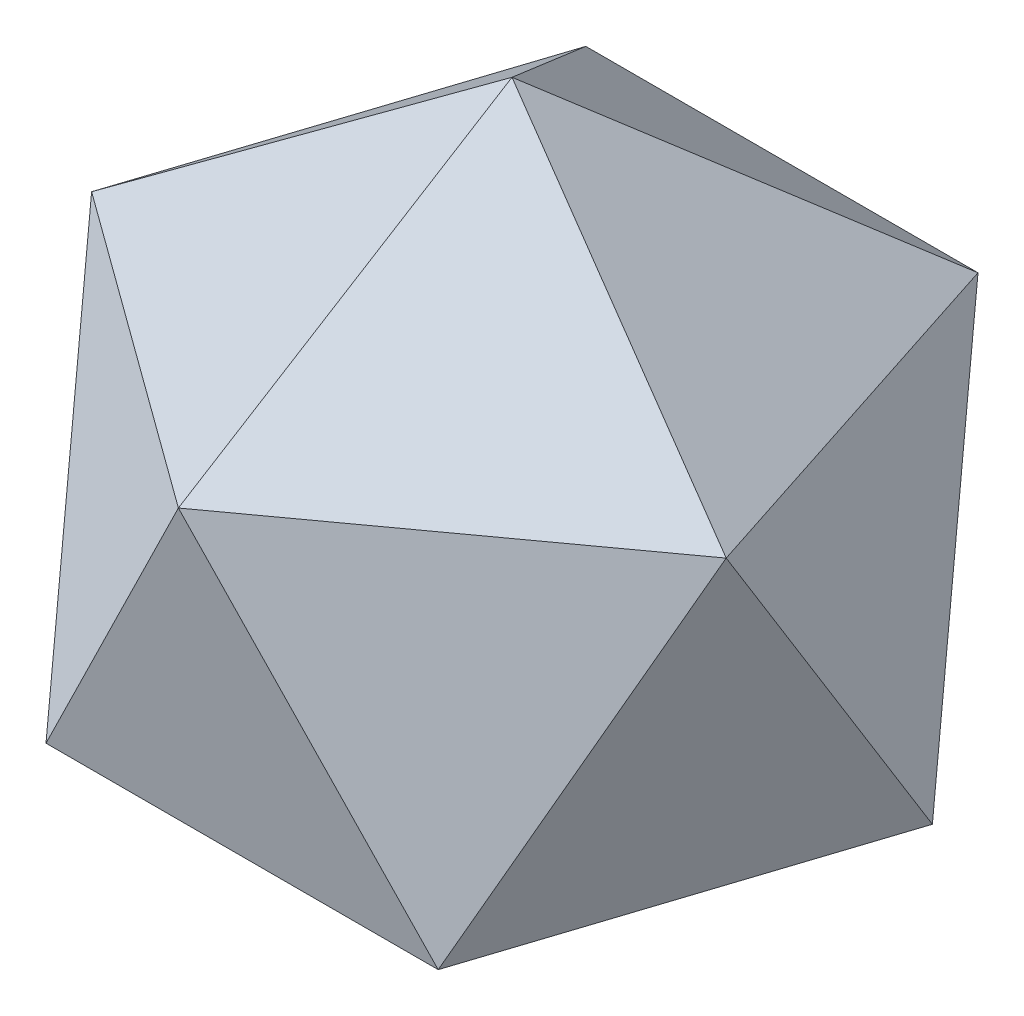
from build123d import *

# Parameters (mm, degrees)
CIRPATTERN1_9_2_ANGLE   = -216
CIRPATTERN1_6_4_ANGLE   = -144
CIRPATTERN1_10_6_ANGLE  = -216
CIRPATTERN1_14_8_ANGLE  = -288
CIRPATTERN1_13_11_ANGLE = -288
CIRPATTERN1_15_13_ANGLE = -288
CIRPATTERN1_16_15_ANGLE = -288
CIRPATTERN1_11_17_ANGLE = -216
CIRPATTERN1_8_19_ANGLE  = -144
CIRPATTERN1_12_21_ANGLE = -216
CIRPATTERN1_7_23_ANGLE  = -144
CIRPATTERN1_3_25_ANGLE  = -72
CIRPATTERN1_4_27_ANGLE  = -72
CIRPATTERN1_5_32_ANGLE  = -144
CIRPATTERN1_34_ANGLE    = -72
CIRPATTERN1_2_36_ANGLE  = -72


with BuildPart() as body_1:
    # Sketch2 → Surface-Fill1: a flat surface bounded by the sketch
    with BuildSketch(Plane(origin=(3.918568349, -8.726779962, -5.393446629), x_dir=(-0.9341723589627158, -0.303530999103343, -0.18759247408507992), z_dir=(0.3568220897730899, -0.7946544722917661, -0.4911234731884233)), mode=Mode.PRIVATE) as surface_fill1_1_region:
        Polygon((4.194695241, 19.021130326), (4.194695241, -7.26542528), (-18.570129692, 5.877852523), align=None)
    surface_fill1_1 = surface_fill1_1_region.sketch.faces()[0]
    # CirPattern1 9: a copy of that surface (a pattern of surface bodies)
    cirpattern1_9_2 = surface_fill1_1.rotate(Axis((0, 0, 0), (0, 1, 0)), CIRPATTERN1_9_2_ANGLE)
    # Sketch3 → Surface-Fill2: a flat surface bounded by the sketch
    with BuildSketch(Plane(origin=(10.258945124, -3.333333333, -14.120226592), x_dir=(0.8164965809277261, 0.13264791052512165, 0.5619055660577252), z_dir=(-0.5773502691896257, 0.18759247408507984, 0.7946544722917663)), mode=Mode.PRIVATE) as surface_fill2_3_region:
        Polygon((3.532571656, 25.918778373), (13.481164945, 1.587553636), (-12.564590426, 5.137431484), align=None)
    surface_fill2_3 = surface_fill2_3_region.sketch.faces()[0]
    # CirPattern1 6: a copy of that surface (a pattern of surface bodies)
    cirpattern1_6_4 = surface_fill2_3.rotate(Axis((0, 0, 0), (0, 1, 0)), CIRPATTERN1_6_4_ANGLE)
    # Sketch3 → Surface-Fill2: a flat surface bounded by the sketch
    with BuildSketch(Plane(origin=(10.258945124, -3.333333333, -14.120226592), x_dir=(0.8164965809277261, 0.13264791052512165, 0.5619055660577252), z_dir=(-0.5773502691896257, 0.18759247408507984, 0.7946544722917663)), mode=Mode.PRIVATE) as surface_fill2_5_region:
        Polygon((3.532571656, 25.918778373), (13.481164945, 1.587553636), (-12.564590426, 5.137431484), align=None)
    surface_fill2_5 = surface_fill2_5_region.sketch.faces()[0]
    # CirPattern1 10: a copy of that surface (a pattern of surface bodies)
    cirpattern1_10_6 = surface_fill2_5.rotate(Axis((0, 0, 0), (0, 1, 0)), CIRPATTERN1_10_6_ANGLE)
    # Sketch3 → Surface-Fill2: a flat surface bounded by the sketch
    with BuildSketch(Plane(origin=(10.258945124, -3.333333333, -14.120226592), x_dir=(0.8164965809277261, 0.13264791052512165, 0.5619055660577252), z_dir=(-0.5773502691896257, 0.18759247408507984, 0.7946544722917663)), mode=Mode.PRIVATE) as surface_fill2_7_region:
        Polygon((3.532571656, 25.918778373), (13.481164945, 1.587553636), (-12.564590426, 5.137431484), align=None)
    surface_fill2_7 = surface_fill2_7_region.sketch.faces()[0]
    # CirPattern1 14: a copy of that surface (a pattern of surface bodies)
    cirpattern1_14_8 = surface_fill2_7.rotate(Axis((0, 0, 0), (0, 1, 0)), CIRPATTERN1_14_8_ANGLE)
    # Sketch6 → Surface-Fill4: a flat surface bounded by the sketch
    with BuildSketch(Plane(origin=(16.599321899, 22.847006554, -5.393446629), x_dir=(0.8164965809277256, -0.561905566057726, 0.13264791052512173), z_dir=(0.5773502691896265, 0.7946544722917657, -0.1875924740850797)), mode=Mode.PRIVATE) as surface_fill4_9_region:
        Polygon((5.715821007, -11.862416603), (-4.232772282, 12.468808133), (-20.329934365, -8.312538756), align=None)
    surface_fill4_9 = surface_fill4_9_region.sketch.faces()[0]
    # Sketch2 → Surface-Fill1: a flat surface bounded by the sketch
    with BuildSketch(Plane(origin=(3.918568349, -8.726779962, -5.393446629), x_dir=(-0.9341723589627158, -0.303530999103343, -0.18759247408507992), z_dir=(0.3568220897730899, -0.7946544722917661, -0.4911234731884233)), mode=Mode.PRIVATE) as surface_fill1_10_region:
        Polygon((4.194695241, 19.021130326), (4.194695241, -7.26542528), (-18.570129692, 5.877852523), align=None)
    surface_fill1_10 = surface_fill1_10_region.sketch.faces()[0]
    # CirPattern1 13: a copy of that surface (a pattern of surface bodies)
    cirpattern1_13_11 = surface_fill1_10.rotate(Axis((0, 0, 0), (0, 1, 0)), CIRPATTERN1_13_11_ANGLE)
    # Sketch5 → Surface-Fill3: a flat surface bounded by the sketch
    with BuildSketch(Plane(origin=(20.517890248, 4.120226592, -6.666666667), x_dir=(0.2975901052216016, 0.059759490383281426, 0.9528215638740166), z_dir=(-0.9341723589627157, -0.1875924740850806, 0.3035309991033427)), mode=Mode.PRIVATE) as surface_fill3_12_region:
        Polygon((-11.989131764, 19.33536107), (-0.255203491, -4.186924808), (14.248729497, 17.736098102), align=None)
    surface_fill3_12 = surface_fill3_12_region.sketch.faces()[0]
    # CirPattern1 15: a copy of that surface (a pattern of surface bodies)
    cirpattern1_15_13 = surface_fill3_12.rotate(Axis((0, 0, 0), (0, 1, 0)), CIRPATTERN1_15_13_ANGLE)
    # Sketch6 → Surface-Fill4: a flat surface bounded by the sketch
    with BuildSketch(Plane(origin=(16.599321899, 22.847006554, -5.393446629), x_dir=(0.8164965809277256, -0.561905566057726, 0.13264791052512173), z_dir=(0.5773502691896265, 0.7946544722917657, -0.1875924740850797)), mode=Mode.PRIVATE) as surface_fill4_14_region:
        Polygon((5.715821007, -11.862416603), (-4.232772282, 12.468808133), (-20.329934365, -8.312538756), align=None)
    surface_fill4_14 = surface_fill4_14_region.sketch.faces()[0]
    # CirPattern1 16: a copy of that surface (a pattern of surface bodies)
    cirpattern1_16_15 = surface_fill4_14.rotate(Axis((0, 0, 0), (0, 1, 0)), CIRPATTERN1_16_15_ANGLE)
    # Sketch5 → Surface-Fill3: a flat surface bounded by the sketch
    with BuildSketch(Plane(origin=(20.517890248, 4.120226592, -6.666666667), x_dir=(0.2975901052216016, 0.059759490383281426, 0.9528215638740166), z_dir=(-0.9341723589627157, -0.1875924740850806, 0.3035309991033427)), mode=Mode.PRIVATE) as surface_fill3_16_region:
        Polygon((-11.989131764, 19.33536107), (-0.255203491, -4.186924808), (14.248729497, 17.736098102), align=None)
    surface_fill3_16 = surface_fill3_16_region.sketch.faces()[0]
    # CirPattern1 11: a copy of that surface (a pattern of surface bodies)
    cirpattern1_11_17 = surface_fill3_16.rotate(Axis((0, 0, 0), (0, 1, 0)), CIRPATTERN1_11_17_ANGLE)
    # Sketch6 → Surface-Fill4: a flat surface bounded by the sketch
    with BuildSketch(Plane(origin=(16.599321899, 22.847006554, -5.393446629), x_dir=(0.8164965809277256, -0.561905566057726, 0.13264791052512173), z_dir=(0.5773502691896265, 0.7946544722917657, -0.1875924740850797)), mode=Mode.PRIVATE) as surface_fill4_18_region:
        Polygon((5.715821007, -11.862416603), (-4.232772282, 12.468808133), (-20.329934365, -8.312538756), align=None)
    surface_fill4_18 = surface_fill4_18_region.sketch.faces()[0]
    # CirPattern1 8: a copy of that surface (a pattern of surface bodies)
    cirpattern1_8_19 = surface_fill4_18.rotate(Axis((0, 0, 0), (0, 1, 0)), CIRPATTERN1_8_19_ANGLE)
    # Sketch6 → Surface-Fill4: a flat surface bounded by the sketch
    with BuildSketch(Plane(origin=(16.599321899, 22.847006554, -5.393446629), x_dir=(0.8164965809277256, -0.561905566057726, 0.13264791052512173), z_dir=(0.5773502691896265, 0.7946544722917657, -0.1875924740850797)), mode=Mode.PRIVATE) as surface_fill4_20_region:
        Polygon((5.715821007, -11.862416603), (-4.232772282, 12.468808133), (-20.329934365, -8.312538756), align=None)
    surface_fill4_20 = surface_fill4_20_region.sketch.faces()[0]
    # CirPattern1 12: a copy of that surface (a pattern of surface bodies)
    cirpattern1_12_21 = surface_fill4_20.rotate(Axis((0, 0, 0), (0, 1, 0)), CIRPATTERN1_12_21_ANGLE)
    # Sketch5 → Surface-Fill3: a flat surface bounded by the sketch
    with BuildSketch(Plane(origin=(20.517890248, 4.120226592, -6.666666667), x_dir=(0.2975901052216016, 0.059759490383281426, 0.9528215638740166), z_dir=(-0.9341723589627157, -0.1875924740850806, 0.3035309991033427)), mode=Mode.PRIVATE) as surface_fill3_22_region:
        Polygon((-11.989131764, 19.33536107), (-0.255203491, -4.186924808), (14.248729497, 17.736098102), align=None)
    surface_fill3_22 = surface_fill3_22_region.sketch.faces()[0]
    # CirPattern1 7: a copy of that surface (a pattern of surface bodies)
    cirpattern1_7_23 = surface_fill3_22.rotate(Axis((0, 0, 0), (0, 1, 0)), CIRPATTERN1_7_23_ANGLE)
    # Sketch5 → Surface-Fill3: a flat surface bounded by the sketch
    with BuildSketch(Plane(origin=(20.517890248, 4.120226592, -6.666666667), x_dir=(0.2975901052216016, 0.059759490383281426, 0.9528215638740166), z_dir=(-0.9341723589627157, -0.1875924740850806, 0.3035309991033427)), mode=Mode.PRIVATE) as surface_fill3_24_region:
        Polygon((-11.989131764, 19.33536107), (-0.255203491, -4.186924808), (14.248729497, 17.736098102), align=None)
    surface_fill3_24 = surface_fill3_24_region.sketch.faces()[0]
    # CirPattern1 3: a copy of that surface (a pattern of surface bodies)
    cirpattern1_3_25 = surface_fill3_24.rotate(Axis((0, 0, 0), (0, 1, 0)), CIRPATTERN1_3_25_ANGLE)
    # Sketch6 → Surface-Fill4: a flat surface bounded by the sketch
    with BuildSketch(Plane(origin=(16.599321899, 22.847006554, -5.393446629), x_dir=(0.8164965809277256, -0.561905566057726, 0.13264791052512173), z_dir=(0.5773502691896265, 0.7946544722917657, -0.1875924740850797)), mode=Mode.PRIVATE) as surface_fill4_26_region:
        Polygon((5.715821007, -11.862416603), (-4.232772282, 12.468808133), (-20.329934365, -8.312538756), align=None)
    surface_fill4_26 = surface_fill4_26_region.sketch.faces()[0]
    # CirPattern1 4: a copy of that surface (a pattern of surface bodies)
    cirpattern1_4_27 = surface_fill4_26.rotate(Axis((0, 0, 0), (0, 1, 0)), CIRPATTERN1_4_27_ANGLE)
    # Sketch2 → Surface-Fill1: a flat surface bounded by the sketch
    with BuildSketch(Plane(origin=(3.918568349, -8.726779962, -5.393446629), x_dir=(-0.9341723589627158, -0.303530999103343, -0.18759247408507992), z_dir=(0.3568220897730899, -0.7946544722917661, -0.4911234731884233)), mode=Mode.PRIVATE) as surface_fill1_28_region:
        Polygon((4.194695241, 19.021130326), (4.194695241, -7.26542528), (-18.570129692, 5.877852523), align=None)
    surface_fill1_28 = surface_fill1_28_region.sketch.faces()[0]
    # Sketch3 → Surface-Fill2: a flat surface bounded by the sketch
    with BuildSketch(Plane(origin=(10.258945124, -3.333333333, -14.120226592), x_dir=(0.8164965809277261, 0.13264791052512165, 0.5619055660577252), z_dir=(-0.5773502691896257, 0.18759247408507984, 0.7946544722917663)), mode=Mode.PRIVATE) as surface_fill2_29_region:
        Polygon((3.532571656, 25.918778373), (13.481164945, 1.587553636), (-12.564590426, 5.137431484), align=None)
    surface_fill2_29 = surface_fill2_29_region.sketch.faces()[0]
    # Sketch5 → Surface-Fill3: a flat surface bounded by the sketch
    with BuildSketch(Plane(origin=(20.517890248, 4.120226592, -6.666666667), x_dir=(0.2975901052216016, 0.059759490383281426, 0.9528215638740166), z_dir=(-0.9341723589627157, -0.1875924740850806, 0.3035309991033427)), mode=Mode.PRIVATE) as surface_fill3_30_region:
        Polygon((-11.989131764, 19.33536107), (-0.255203491, -4.186924808), (14.248729497, 17.736098102), align=None)
    surface_fill3_30 = surface_fill3_30_region.sketch.faces()[0]
    # Sketch2 → Surface-Fill1: a flat surface bounded by the sketch
    with BuildSketch(Plane(origin=(3.918568349, -8.726779962, -5.393446629), x_dir=(-0.9341723589627158, -0.303530999103343, -0.18759247408507992), z_dir=(0.3568220897730899, -0.7946544722917661, -0.4911234731884233)), mode=Mode.PRIVATE) as surface_fill1_31_region:
        Polygon((4.194695241, 19.021130326), (4.194695241, -7.26542528), (-18.570129692, 5.877852523), align=None)
    surface_fill1_31 = surface_fill1_31_region.sketch.faces()[0]
    # CirPattern1 5: a copy of that surface (a pattern of surface bodies)
    cirpattern1_5_32 = surface_fill1_31.rotate(Axis((0, 0, 0), (0, 1, 0)), CIRPATTERN1_5_32_ANGLE)
    # Sketch2 → Surface-Fill1: a flat surface bounded by the sketch
    with BuildSketch(Plane(origin=(3.918568349, -8.726779962, -5.393446629), x_dir=(-0.9341723589627158, -0.303530999103343, -0.18759247408507992), z_dir=(0.3568220897730899, -0.7946544722917661, -0.4911234731884233)), mode=Mode.PRIVATE) as surface_fill1_33_region:
        Polygon((4.194695241, 19.021130326), (4.194695241, -7.26542528), (-18.570129692, 5.877852523), align=None)
    surface_fill1_33 = surface_fill1_33_region.sketch.faces()[0]
    # CirPattern1: a copy of that surface (a pattern of surface bodies)
    cirpattern1_34 = surface_fill1_33.rotate(Axis((0, 0, 0), (0, 1, 0)), CIRPATTERN1_34_ANGLE)
    # Sketch3 → Surface-Fill2: a flat surface bounded by the sketch
    with BuildSketch(Plane(origin=(10.258945124, -3.333333333, -14.120226592), x_dir=(0.8164965809277261, 0.13264791052512165, 0.5619055660577252), z_dir=(-0.5773502691896257, 0.18759247408507984, 0.7946544722917663)), mode=Mode.PRIVATE) as surface_fill2_35_region:
        Polygon((3.532571656, 25.918778373), (13.481164945, 1.587553636), (-12.564590426, 5.137431484), align=None)
    surface_fill2_35 = surface_fill2_35_region.sketch.faces()[0]
    # CirPattern1 2: a copy of that surface (a pattern of surface bodies)
    cirpattern1_2_36 = surface_fill2_35.rotate(Axis((0, 0, 0), (0, 1, 0)), CIRPATTERN1_2_36_ANGLE)
    # Surface-Knit1: the surfaces knitted into a closed skin and filled: a solid
    add(Solid(Shell(Face.sew_faces(cirpattern1_9_2.faces() + cirpattern1_6_4.faces() + cirpattern1_10_6.faces() + cirpattern1_14_8.faces() + surface_fill4_9.faces() + cirpattern1_13_11.faces() + cirpattern1_15_13.faces() + cirpattern1_16_15.faces() + cirpattern1_11_17.faces() + cirpattern1_8_19.faces() + cirpattern1_12_21.faces() + cirpattern1_7_23.faces() + cirpattern1_3_25.faces() + cirpattern1_4_27.faces() + surface_fill1_28.faces() + surface_fill2_29.faces() + surface_fill3_30.faces() + cirpattern1_5_32.faces() + cirpattern1_34.faces() + cirpattern1_2_36.faces())[0])))


solid = body_1.part
